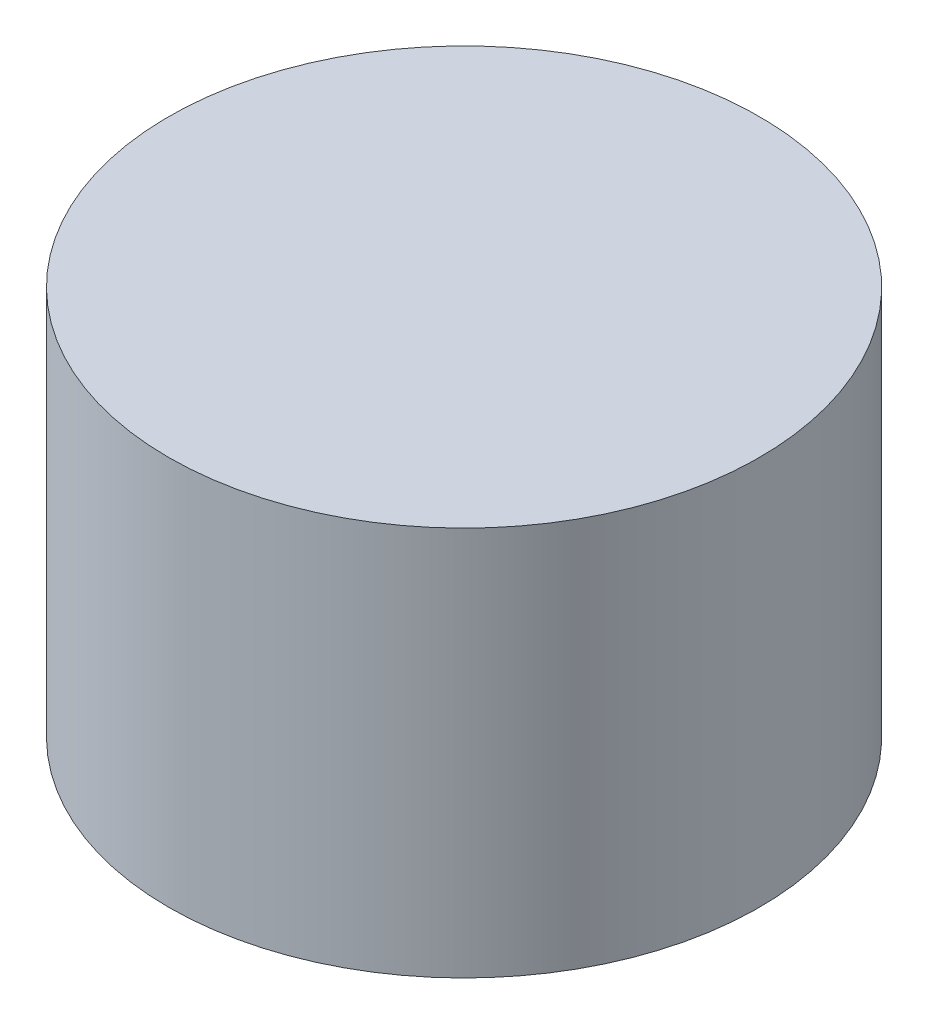
from build123d import *

# Parameters (mm, degrees)
SKETCH1_R           = 4.812919
BOSS_EXTRUDE1_DEPTH = 6.35


with BuildPart() as part:
    # Sketch1 → Boss-Extrude1 (new body)
    with BuildSketch(Plane(origin=(0, 0, 0), x_dir=(1, 0, 0), z_dir=(0, 1, 0))):
        Circle(SKETCH1_R)
    extrude(amount=BOSS_EXTRUDE1_DEPTH)


solid = part.part
